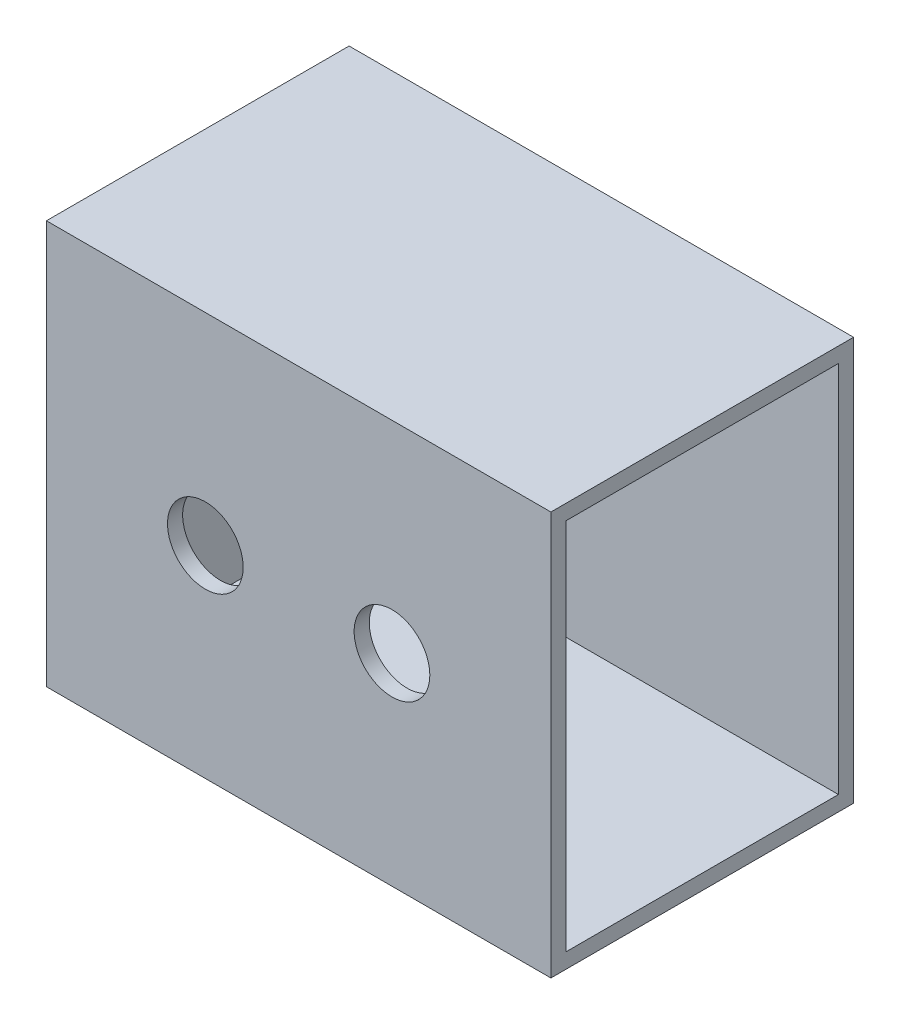
from build123d import *

# Parameters (mm, degrees)
SKETCH1_W           = 100
SKETCH1_H           = 80
SKETCH1_W_2         = 92.5
SKETCH1_H_2         = 74
BOSS_EXTRUDE1_DEPTH = 60
SKETCH2_W           = 92.5
SKETCH2_H           = 3
BOSS_EXTRUDE2_DEPTH = 77
SKETCH3_W           = 92.5
SKETCH3_H           = 3
BOSS_EXTRUDE3_DEPTH = 77
SKETCH4_W           = 54
SKETCH4_H           = 74
CUT_EXTRUDE1_DEPTH  = 77
SKETCH7_R           = 7.5
CUT_EXTRUDE2_DEPTH  = 10


with BuildPart() as part:
    # Sketch1 → Boss-Extrude1 (new body)
    with BuildSketch(Plane.XY):
        Rectangle(SKETCH1_W, SKETCH1_H)
        Rectangle(SKETCH1_W_2, SKETCH1_H_2, mode=Mode.SUBTRACT)
    extrude(amount=BOSS_EXTRUDE1_DEPTH)

    # Sketch2 → Boss-Extrude2 (add)
    with BuildSketch(Plane(origin=(0, -37, 0), x_dir=(1, 0, 0), z_dir=(0, 1, 0))):
        with Locations((0, -1.5)):
            Rectangle(SKETCH2_W, SKETCH2_H)
    extrude(amount=BOSS_EXTRUDE2_DEPTH)

    # Sketch3 → Boss-Extrude3 (add)
    with BuildSketch(Plane(origin=(0, -37, 0), x_dir=(1, 0, 0), z_dir=(0, 1, 0))):
        with Locations((0, -58.5)):
            Rectangle(SKETCH3_W, SKETCH3_H)
    extrude(amount=BOSS_EXTRUDE3_DEPTH)

    # Sketch4 → Cut-Extrude1 (cut)
    with BuildSketch(Plane(origin=(50, 0, 0), x_dir=(0, 0, -1), z_dir=(1, 0, 0))):
        with Locations((-30, 0)):
            Rectangle(SKETCH4_W, SKETCH4_H)
    extrude(amount=-CUT_EXTRUDE1_DEPTH, mode=Mode.SUBTRACT)

    # Sketch7 → Cut-Extrude2 (cut)
    with BuildSketch(Plane.XY.offset(60)):
        with BuildLine():
            ThreePointArc((11, 0), (18.5, -7.5), (26, 0))
            Line((26, 0), (18.5, 0))
            Line((18.5, 0), (11, 0))
        make_face()
        with BuildLine():
            Line((18.5, 0), (26, 0))
            ThreePointArc((26, 0), (18.5, 7.5), (11, 0))
            Line((11, 0), (18.5, 0))
        make_face()
        with Locations((-18.5, 0)):
            Circle(SKETCH7_R)
    extrude(amount=-CUT_EXTRUDE2_DEPTH, mode=Mode.SUBTRACT)


solid = part.part
